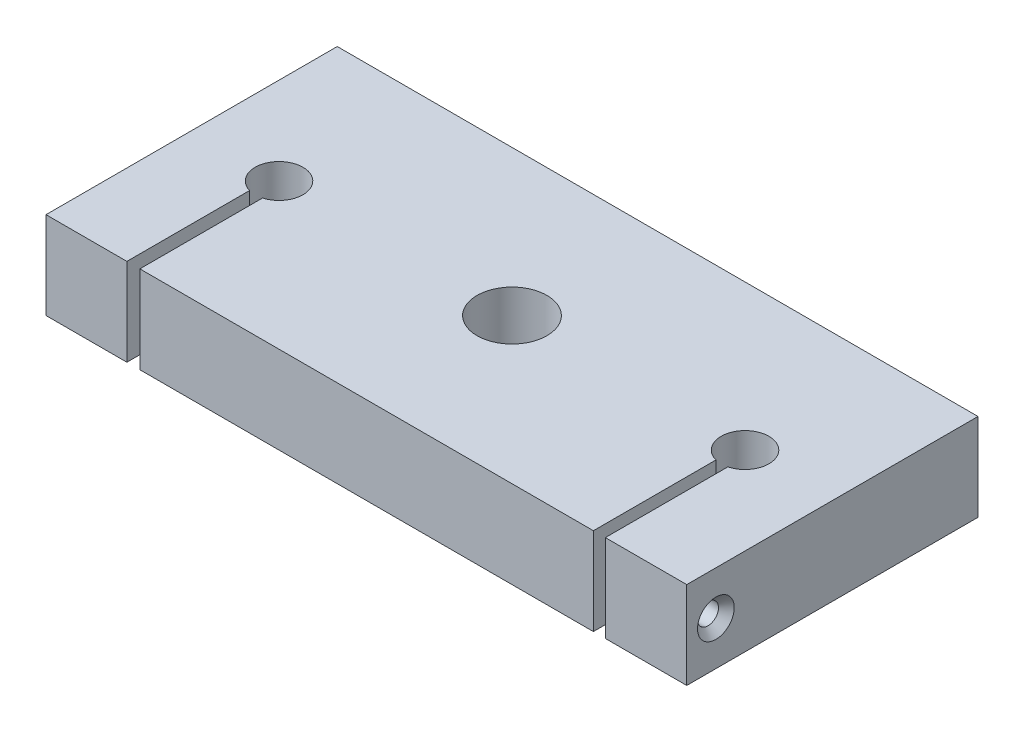
from build123d import *

# Parameters (mm, degrees)
SKETCH1_W                                       = 110
SKETCH1_H                                       = 50
SKETCH1_R                                       = 6
BOSS_EXTRUDE2_DEPTH                             = 15
CUT_EXTRUDE1_DEPTH                              = 24
CSK_FOR_M3_FLAT_HEAD_MACHINE_SCREW1_D           = 3.6
CSK_FOR_M3_FLAT_HEAD_MACHINE_SCREW1_DEPTH       = 13.886032024
CSK_FOR_M3_FLAT_HEAD_MACHINE_SCREW1_CSINK_D     = 6.3
CSK_FOR_M3_FLAT_HEAD_MACHINE_SCREW1_CSINK_ANGLE = 90
CSK_FOR_M3_FLAT_HEAD_MACHINE_SCREW1_TIP         = 1.081549114
CSK_FOR_M3_FLAT_HEAD_MACHINE_SCREW2_D           = 3.6
CSK_FOR_M3_FLAT_HEAD_MACHINE_SCREW2_DEPTH       = 13.975
CSK_FOR_M3_FLAT_HEAD_MACHINE_SCREW2_CSINK_D     = 6.3
CSK_FOR_M3_FLAT_HEAD_MACHINE_SCREW2_CSINK_ANGLE = 90
CSK_FOR_M3_FLAT_HEAD_MACHINE_SCREW2_TIP         = 1.081549114
TAP_DRILL_FOR_M3X0_5_TAP1_D                     = 2.5


with BuildPart() as part:
    # Sketch1 → Boss-Extrude2 (new body)
    with BuildSketch(Plane(origin=(0, 0, 0), x_dir=(1, 0, 0), z_dir=(0, 1, 0))):
        Rectangle(SKETCH1_W, SKETCH1_H)
        Circle(SKETCH1_R, mode=Mode.SUBTRACT)
    extrude(amount=BOSS_EXTRUDE2_DEPTH)

    # Sketch2 → Cut-Extrude1 (cut)
    with BuildSketch(Plane(origin=(0, 15, 0), x_dir=(1, 0, 0), z_dir=(0, 1, 0))):
        with BuildLine():
            Line((-41.113967976, -25), (-38.886032024, -25))
            Line((-38.886032024, -25), (-38.886032024, -3.938852881))
            ThreePointArc((-38.886032024, -3.938852881), (-40, 4.106913882), (-41.113967976, -3.938852881))
            Line((-41.113967976, -3.938852881), (-41.113967976, -25))
        make_face()
        with BuildLine():
            Line((38.975, -25), (41.025, -25))
            Line((41.025, -25), (41.025, -3.962894048))
            ThreePointArc((41.025, -3.962894048), (40, 4.106913882), (38.975, -3.962894048))
            Line((38.975, -3.962894048), (38.975, -25))
        make_face()
    extrude(amount=-CUT_EXTRUDE1_DEPTH, mode=Mode.SUBTRACT)

    # CSK for M3 Flat Head Machine Screw1
    with Locations(Plane.ZY.offset(55)):
        with Locations((20, 7.5)):
            CounterSinkHole(CSK_FOR_M3_FLAT_HEAD_MACHINE_SCREW1_D / 2, CSK_FOR_M3_FLAT_HEAD_MACHINE_SCREW1_CSINK_D / 2, depth=CSK_FOR_M3_FLAT_HEAD_MACHINE_SCREW1_DEPTH, counter_sink_angle=CSK_FOR_M3_FLAT_HEAD_MACHINE_SCREW1_CSINK_ANGLE)
            with Locations((0, 0, -(CSK_FOR_M3_FLAT_HEAD_MACHINE_SCREW1_DEPTH + CSK_FOR_M3_FLAT_HEAD_MACHINE_SCREW1_TIP / 2))):  # 118° drill point
                Cone(0, CSK_FOR_M3_FLAT_HEAD_MACHINE_SCREW1_D / 2, CSK_FOR_M3_FLAT_HEAD_MACHINE_SCREW1_TIP, mode=Mode.SUBTRACT)

    # CSK for M3 Flat Head Machine Screw2
    with Locations(Plane(origin=(55, 0, 0), x_dir=(0, 0, -1), z_dir=(1, 0, 0))):
        with Locations((-20, 7.5)):
            CounterSinkHole(CSK_FOR_M3_FLAT_HEAD_MACHINE_SCREW2_D / 2, CSK_FOR_M3_FLAT_HEAD_MACHINE_SCREW2_CSINK_D / 2, depth=CSK_FOR_M3_FLAT_HEAD_MACHINE_SCREW2_DEPTH, counter_sink_angle=CSK_FOR_M3_FLAT_HEAD_MACHINE_SCREW2_CSINK_ANGLE)
            with Locations((0, 0, -(CSK_FOR_M3_FLAT_HEAD_MACHINE_SCREW2_DEPTH + CSK_FOR_M3_FLAT_HEAD_MACHINE_SCREW2_TIP / 2))):  # 118° drill point
                Cone(0, CSK_FOR_M3_FLAT_HEAD_MACHINE_SCREW2_D / 2, CSK_FOR_M3_FLAT_HEAD_MACHINE_SCREW2_TIP, mode=Mode.SUBTRACT)

    # Tap Drill for M3x0.5 Tap1 (through all)
    with Locations(Plane.ZY.offset(38.886032024)):
        with Locations((20, 7.5)):
            Hole(TAP_DRILL_FOR_M3X0_5_TAP1_D / 2)


solid = part.part
